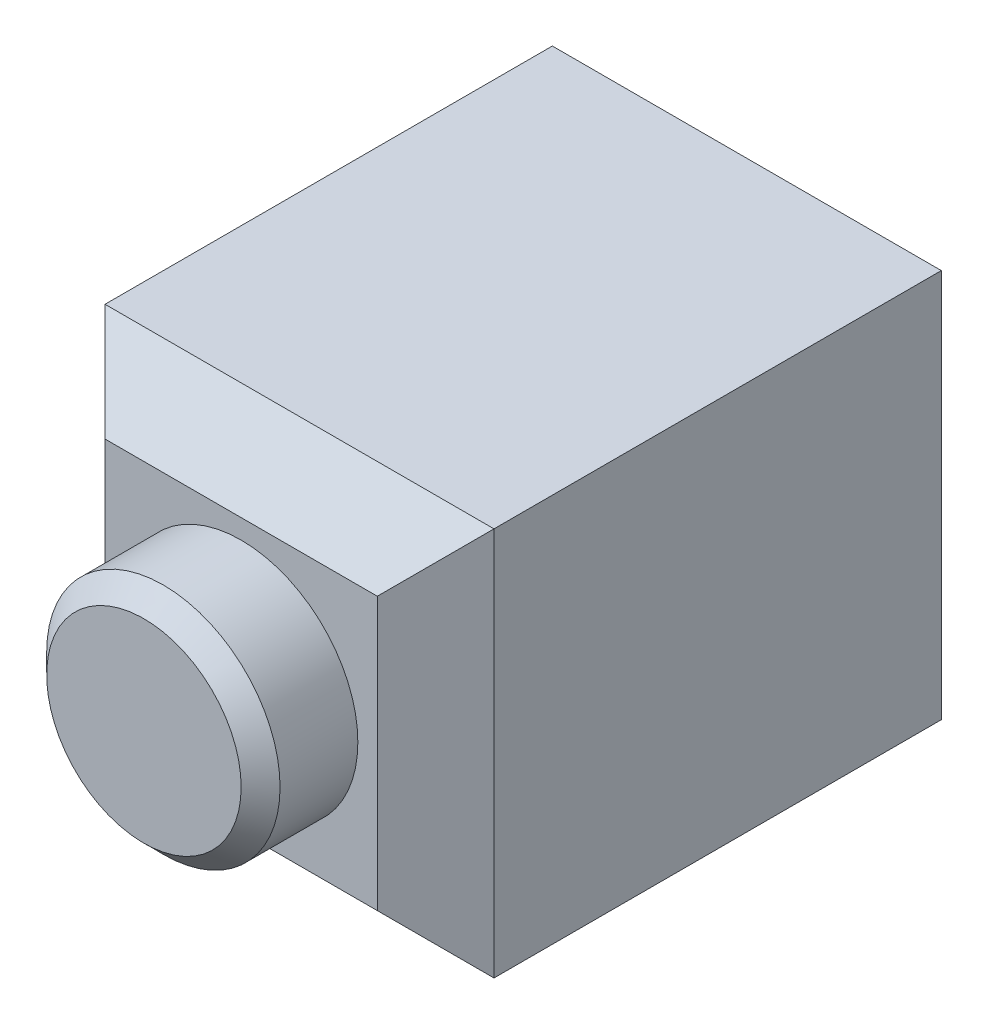
from build123d import *

# Parameters (mm, degrees)
SKETCH1_W      = 20
SKETCH1_H      = 20
EXTRUDE1_DEPTH = 26
CHAMFER1_SIZE  = 3
SKETCH3_R      = 6
EXTRUDE3_DEPTH = 5
CHAMFER2_SIZE  = 1


with BuildPart() as part:
    # Sketch1 → Extrude1 (new body)
    with BuildSketch(Plane.XY):
        with Locations((-7.709896983, -3.408922001)):
            Rectangle(SKETCH1_W, SKETCH1_H)
    extrude(amount=EXTRUDE1_DEPTH)

    # Chamfer1
    chamfer1_edges = [part.edges().sort_by_distance(p)[0] for p in [
        (2.290103017, -3.408922001, 26),
        (-7.709896983, 6.591077999, 26),
        (-17.709896983, -3.408922001, 26),
        (-7.709896983, -13.408922001, 26),
    ]]
    chamfer(chamfer1_edges, length=CHAMFER1_SIZE)

    # Sketch3 → Extrude3 (add)
    with BuildSketch(Plane.XY.offset(26)):
        with Locations((-7.709896983, -3.408922001)):
            Circle(SKETCH3_R)
    extrude(amount=EXTRUDE3_DEPTH)

    # Chamfer2
    chamfer2_edges = [part.edges().sort_by_distance(p)[0] for p in [
        (-13.709896983, -3.408922001, 31),
    ]]
    chamfer(chamfer2_edges, length=CHAMFER2_SIZE)


solid = part.part
